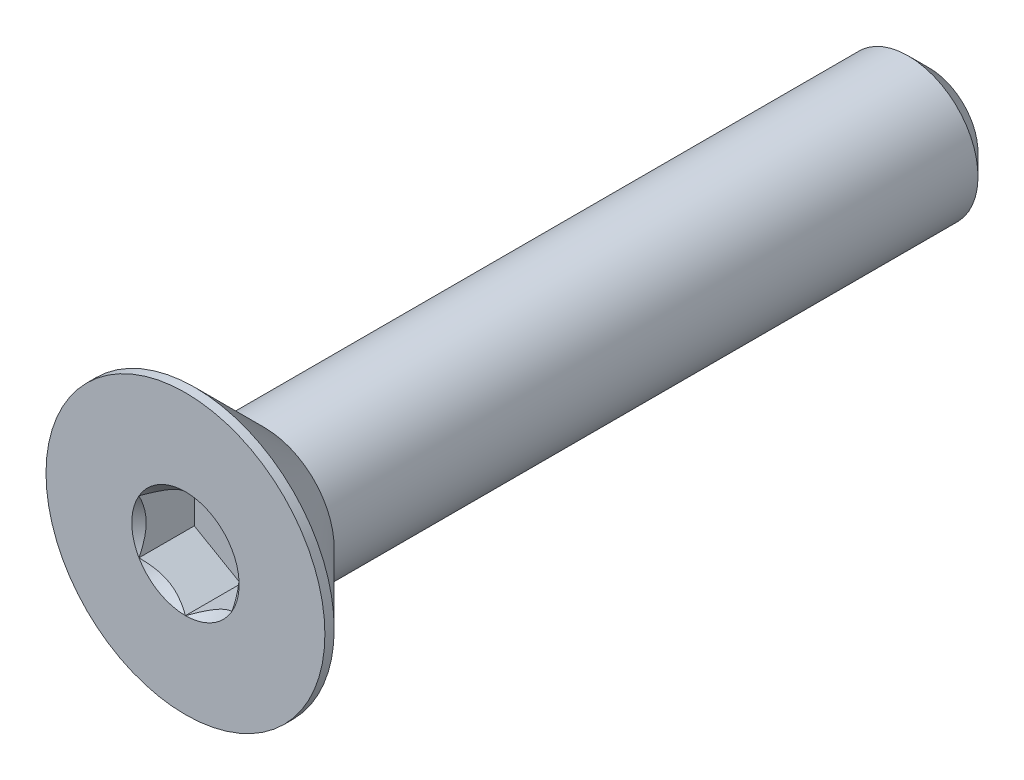
from build123d import *

# Parameters (mm, degrees)
SKETCH3_W          = 16
SKETCH3_H          = 1.5
CHAMFER1_SIZE      = 0.45
CUT_EXTRUDE1_DEPTH = 1.19


with BuildPart() as part:
    # Sketch3 → Revolve1 (revolve)
    with BuildSketch(Plane(origin=(0, 0, 0), x_dir=(0, 0, -1), z_dir=(1, 0, 0))):
        with Locations((0, 0.75)):
            Rectangle(SKETCH3_W, SKETCH3_H)
    revolve(axis=Axis((0, 0, -8), (0, 0, 1)))

    # Chamfer1
    chamfer1_edges = [part.edges().sort_by_distance(p)[0] for p in [
        (0, -1.5, -8),
    ]]
    chamfer(chamfer1_edges, length=CHAMFER1_SIZE)

    # Sketch6 → Revolve2 (revolve)
    with BuildSketch(Plane(origin=(0, 0, 0), x_dir=(0, 0, -1), z_dir=(1, 0, 0))):
        Polygon((-8, 3), (-7.8, 3), (-6.3, 1.5), (-6.3, 0), (-8, 0), align=None)
    revolve(axis=Axis((0, 0, -8), (0, 0, 1)))

    # Sketch8 → Cut-Extrude1 (cut)
    with BuildSketch(Plane.XY.offset(8)):
        Polygon((0, 1.154700538), (-1, 0.577350269), (-1, -0.577350269), (0, -1.154700538), (1, -0.577350269), (1, 0.577350269), align=None)
    extrude(amount=-CUT_EXTRUDE1_DEPTH, mode=Mode.SUBTRACT)

    # Cut-Extrude2 cone 1 section (through the dimple's axis) → Cut-Extrude2 (revolve, cut)
    with BuildSketch(Plane(origin=(0, 0, 8), x_dir=(0, -1, 0), z_dir=(1, 0, 0))):
        Polygon((0, 0), (1.154700538, 0), (0, 1.154700538), align=None)
    revolve(axis=Axis((0, 0, 8), (0, 0, -1)), mode=Mode.SUBTRACT)


solid = part.part
